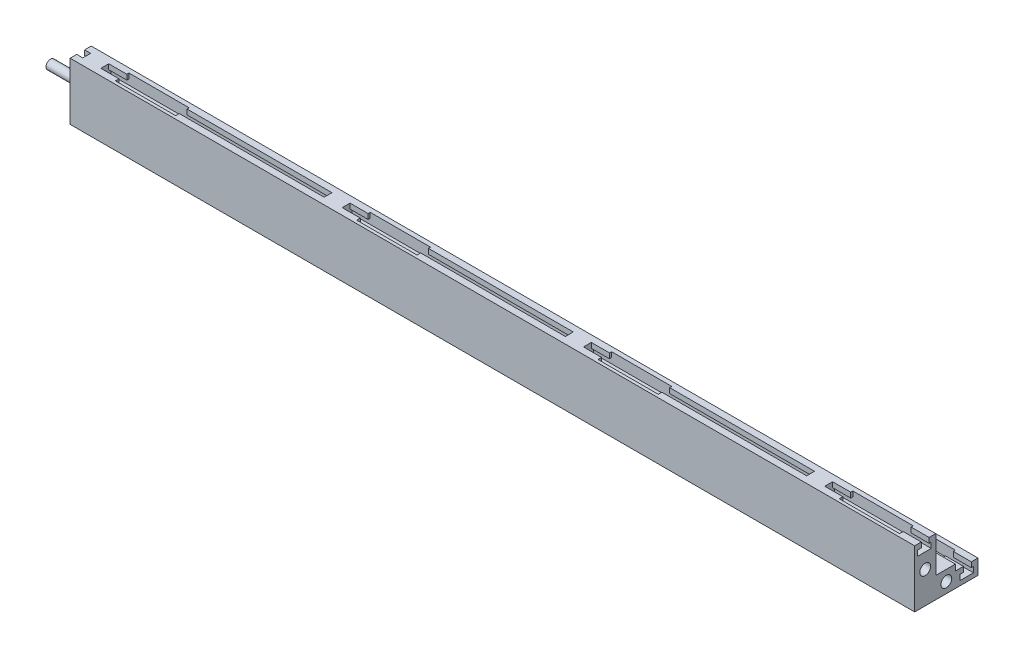
from build123d import *

# Parameters (mm, degrees)
BOSS_EXTRUDE1_DEPTH = 140
SKETCH1_5_R         = 0.75
BOSS_EXTRUDE2_DEPTH = 5
SKETCH2_R           = 0.9
SKETCH2_R_2         = 0.75
CUT_EXTRUDE1_DEPTH  = 6
SKETCH3_W           = 0.25
SKETCH3_H           = 1
CUT_EXTRUDE2_DEPTH  = 171.461242575
SKETCH4_W           = 10
SKETCH4_H           = 2.25
CUT_EXTRUDE3_DEPTH  = 86.659037056
SKETCH6_W           = 10
SKETCH6_H           = 2.25
CUT_EXTRUDE4_DEPTH  = 86.755295051
BOSS_EXTRUDE3_REACH = 87.755
SKETCH7_W           = 3
SKETCH7_H           = 2.25
SKETCH8_W           = 3
SKETCH8_H           = 2.25
BOSS_EXTRUDE4_DEPTH = 1.75


with BuildPart() as part:
    # Sketch1 → Boss-Extrude1 (new body)
    with BuildSketch(Plane(origin=(-58.146340827, 0, 0), x_dir=(0, 0, -1), z_dir=(1, 0, 0))):
        Polygon((-20.52887033, 86.340306989), (-21.62887033, 86.340306989), (-21.62887033, 85.490306989), (-21.27887033, 85.490306989), (-21.27887033, 84.590306989), (-23.52887033, 84.590306989), (-23.52887033, 85.490306989), (-22.92887033, 85.490306989), (-22.92887033, 86.340306989), (-24.02887033, 86.340306989), (-24.02887033, 76.840306989), (-13.52887033, 76.840306989), (-13.52887033, 79.340306989), (-14.62887033, 79.340306989), (-14.62887033, 78.490306989), (-14.27887033, 78.490306989), (-14.27887033, 77.590306989), (-16.52887033, 77.590306989), (-16.52887033, 78.490306989), (-15.92887033, 78.490306989), (-15.92887033, 79.340306989), (-17.02887033, 79.340306989), (-17.02887033, 80.340306989), (-20.52887033, 80.340306989), align=None)
    extrude(amount=BOSS_EXTRUDE1_DEPTH)

    # Sketch1_5 → Boss-Extrude2 (add)
    with BuildSketch(Plane(origin=(-58.146340827, 0, 0), x_dir=(0, 0, -1), z_dir=(1, 0, 0))):
        with Locations((-22.27887033, 82.090306989)):
            Circle(SKETCH1_5_R)
        with Locations((-18.77887033, 78.590306989)):
            Circle(SKETCH1_5_R)
    extrude(amount=-BOSS_EXTRUDE2_DEPTH)

    # Sketch2 → Cut-Extrude1 (cut)
    with BuildSketch(Plane(origin=(81.853659173, 0, 0), x_dir=(0, 0, -1), z_dir=(1, 0, 0))):
        with Locations((-22.27887033, 82.090306989)):
            Circle(SKETCH2_R)
        with Locations((-22.27887033, 82.090306989)):
            Circle(SKETCH2_R_2, mode=Mode.SUBTRACT)
        with Locations((-22.27887033, 82.090306989)):
            Circle(SKETCH2_R_2)
        with Locations((-18.77887033, 78.590306989)):
            Circle(SKETCH2_R)
        with Locations((-18.77887033, 78.590306989)):
            Circle(SKETCH2_R_2, mode=Mode.SUBTRACT)
        with Locations((-18.77887033, 78.590306989)):
            Circle(SKETCH2_R_2)
    extrude(amount=-CUT_EXTRUDE1_DEPTH, mode=Mode.SUBTRACT)

    # Sketch3 → Cut-Extrude2 (cut, through all)
    with BuildSketch(Plane(origin=(81.853659173, 0, 0), x_dir=(0, 0, -1), z_dir=(1, 0, 0))):
        with Locations((-17.15387033, 79.840306989)):
            Rectangle(SKETCH3_W, SKETCH3_H)
    extrude(amount=-CUT_EXTRUDE2_DEPTH, mode=Mode.SUBTRACT)

    # Sketch4 → Cut-Extrude3 (cut, through all)
    with BuildSketch(Plane(origin=(0, 84.590306989, 0), x_dir=(1, 0, 0), z_dir=(0, 1, 0))):
        with Locations((73.853659173, -22.40387033)):
            Rectangle(SKETCH4_W, SKETCH4_H)
        with Locations((33.853659173, -22.40387033)):
            Rectangle(SKETCH4_W, SKETCH4_H)
        with Locations((-6.146340827, -22.40387033)):
            Rectangle(SKETCH4_W, SKETCH4_H)
        with Locations((-46.146340827, -22.40387033)):
            Rectangle(SKETCH4_W, SKETCH4_H)
    extrude(amount=CUT_EXTRUDE3_DEPTH, mode=Mode.SUBTRACT)

    # Sketch6 → Cut-Extrude4 (cut, through all)
    with BuildSketch(Plane(origin=(0, 77.590306989, 0), x_dir=(1, 0, 0), z_dir=(0, 1, 0))):
        with Locations((73.853659173, -15.40387033)):
            Rectangle(SKETCH6_W, SKETCH6_H)
        with Locations((33.853659173, -15.40387033)):
            Rectangle(SKETCH6_W, SKETCH6_H)
        with Locations((-6.146340827, -15.40387033)):
            Rectangle(SKETCH6_W, SKETCH6_H)
        with Locations((-46.146340827, -15.40387033)):
            Rectangle(SKETCH6_W, SKETCH6_H)
    extrude(amount=CUT_EXTRUDE4_DEPTH, mode=Mode.SUBTRACT)

    # Boss-Extrude3: up to this face of the body (flat: up to its plane)
    boss_extrude3_end = Plane(part.part.faces().sort_by_distance((11.653659173, 79.340306989, 14.04137033))[0])
    # Sketch7 → Boss-Extrude3 (add, up to the picked face)
    with BuildSketch(Plane(origin=(0, 77.590306989, 0), x_dir=(1, 0, 0), z_dir=(0, 1, 0)), mode=Mode.PRIVATE) as boss_extrude3_sk1:
        with Locations((-55.646340827, -15.40387033)):
            Rectangle(SKETCH7_W, SKETCH7_H)
    boss_extrude3_tool1 = split(extrude(boss_extrude3_sk1.sketch, amount=BOSS_EXTRUDE3_REACH, mode=Mode.PRIVATE), bisect_by=boss_extrude3_end, keep=Keep.BOTH, mode=Mode.PRIVATE)
    # Sketch7 → Boss-Extrude3 (add, up to the picked face)
    with BuildSketch(Plane(origin=(0, 77.590306989, 0), x_dir=(1, 0, 0), z_dir=(0, 1, 0)), mode=Mode.PRIVATE) as boss_extrude3_sk2:
        with Locations((-15.646340827, -15.40387033)):
            Rectangle(SKETCH7_W, SKETCH7_H)
    boss_extrude3_tool2 = split(extrude(boss_extrude3_sk2.sketch, amount=BOSS_EXTRUDE3_REACH, mode=Mode.PRIVATE), bisect_by=boss_extrude3_end, keep=Keep.BOTH, mode=Mode.PRIVATE)
    # Sketch7 → Boss-Extrude3 (add, up to the picked face)
    with BuildSketch(Plane(origin=(0, 77.590306989, 0), x_dir=(1, 0, 0), z_dir=(0, 1, 0)), mode=Mode.PRIVATE) as boss_extrude3_sk3:
        with Locations((24.353659173, -15.40387033)):
            Rectangle(SKETCH7_W, SKETCH7_H)
    boss_extrude3_tool3 = split(extrude(boss_extrude3_sk3.sketch, amount=BOSS_EXTRUDE3_REACH, mode=Mode.PRIVATE), bisect_by=boss_extrude3_end, keep=Keep.BOTH, mode=Mode.PRIVATE)
    # Sketch7 → Boss-Extrude3 (add, up to the picked face)
    with BuildSketch(Plane(origin=(0, 77.590306989, 0), x_dir=(1, 0, 0), z_dir=(0, 1, 0)), mode=Mode.PRIVATE) as boss_extrude3_sk4:
        with Locations((64.353659173, -15.40387033)):
            Rectangle(SKETCH7_W, SKETCH7_H)
    boss_extrude3_tool4 = split(extrude(boss_extrude3_sk4.sketch, amount=BOSS_EXTRUDE3_REACH, mode=Mode.PRIVATE), bisect_by=boss_extrude3_end, keep=Keep.BOTH, mode=Mode.PRIVATE)
    add(boss_extrude3_tool1.solids().sort_by(Axis((-55.646341, 77.590307, 15.40387), (0, 1, 0)))[0])
    add(boss_extrude3_tool2.solids().sort_by(Axis((-15.646341, 77.590307, 15.40387), (0, 1, 0)))[0])
    add(boss_extrude3_tool3.solids().sort_by(Axis((24.353659, 77.590307, 15.40387), (0, 1, 0)))[0])
    add(boss_extrude3_tool4.solids().sort_by(Axis((64.353659, 77.590307, 15.40387), (0, 1, 0)))[0])

    # Sketch8 → Boss-Extrude4 (add)
    with BuildSketch(Plane(origin=(0, 84.590306989, 0), x_dir=(1, 0, 0), z_dir=(0, 1, 0))):
        with Locations((-55.646340827, -22.40387033)):
            Rectangle(SKETCH8_W, SKETCH8_H)
        with Locations((-15.646340827, -22.40387033)):
            Rectangle(SKETCH8_W, SKETCH8_H)
        with Locations((24.353659173, -22.40387033)):
            Rectangle(SKETCH8_W, SKETCH8_H)
        with Locations((64.353659173, -22.40387033)):
            Rectangle(SKETCH8_W, SKETCH8_H)
    extrude(amount=BOSS_EXTRUDE4_DEPTH)


solid = part.part
